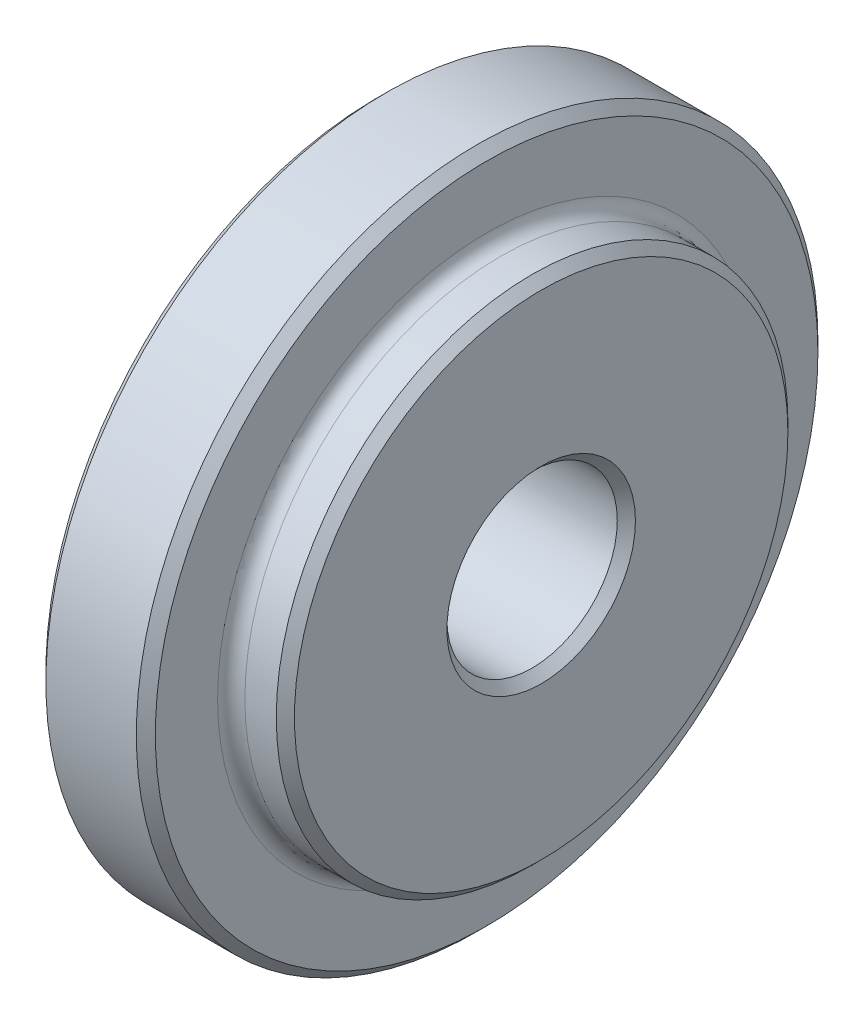
from build123d import *

# Parameters (mm, degrees)
SKETCH3_R          = 4.7625
CUT_EXTRUDE1_DEPTH = 13.192
CHAMFER1_SIZE      = 0.508


with BuildPart() as part:
    # Sketch2 → Revolve1 (revolve)
    with BuildSketch(Plane.XY):
        with BuildLine():
            Line((27.553988289, 50.300658572), (27.553988289, 36.559258572))
            Line((27.553988289, 36.559258572), (33.638296362, 36.559258572))
            Line((33.638296362, 36.559258572), (39.745988289, 36.571958572))
            Line((39.745988289, 36.571958572), (39.745988289, 50.351458572))
            Line((39.745988289, 50.351458572), (39.237988289, 50.859458572))
            Line((39.237988289, 50.859458572), (37.483216953, 50.859458572))
            ThreePointArc((37.483216953, 50.859458572), (36.944383174, 51.073319594), (36.697988289, 51.598074717))
            Line((36.697988289, 51.598074717), (36.697988289, 55.077874717))
            Line((36.697988289, 55.077874717), (36.166604435, 55.609258572))
            Line((36.166604435, 55.609258572), (31.109988289, 55.609258572))
            Line((31.109988289, 55.609258572), (30.601988289, 55.101258572))
            Line((30.601988289, 55.101258572), (30.601988289, 51.621458572))
            ThreePointArc((30.601988289, 51.621458572), (30.371364168, 51.064682692), (29.814588289, 50.834058572))
            Line((29.814588289, 50.834058572), (28.061988289, 50.834058572))
            Line((28.061988289, 50.834058572), (27.553988289, 50.300658572))
        make_face()
    revolve(axis=Axis((33.638296362, 36.559258572, 0), (-1, 0, 0)))

    # Sketch3 → Cut-Extrude1 (cut, through all)
    with BuildSketch(Plane.ZY.offset(-27.553988289)):
        with Locations((0, 36.559258572)):
            Circle(SKETCH3_R)
    extrude(amount=-CUT_EXTRUDE1_DEPTH, mode=Mode.SUBTRACT)

    # Chamfer1
    chamfer1_edges = [part.edges().sort_by_distance(p)[0] for p in [
        (39.745988289, 36.559258572, -4.7625),
        (27.553988289, 36.559258572, -4.7625),
    ]]
    chamfer(chamfer1_edges, length=CHAMFER1_SIZE)


solid = part.part
